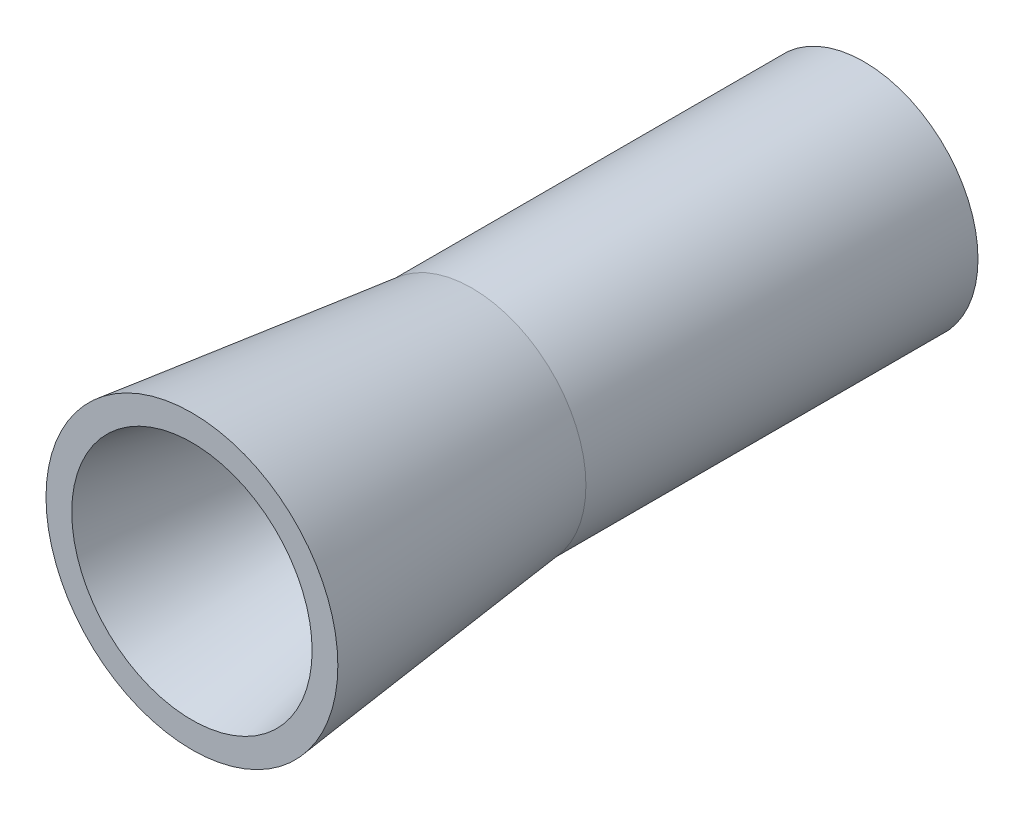
from build123d import *


with BuildPart() as part:
    # Sketch56 → Revolve1 (revolve)
    with BuildSketch(Plane(origin=(0, 0, 0), x_dir=(0, 0, -1), z_dir=(1, 0, 0))):
        Polygon((954.248849632, 397.569923116), (954.248849632, 372.871172083), (1200.354261712, 320.827375263), (1453.24665134, 320.827375263), (1599.130492084, 336.71334147), (1599.130492084, 366.85463088), (1222.967200249, 366.85463088), align=None)
    revolve(axis=Axis((0, 257.561673271, -1614.305416091), (0, 0, 1)))


solid = part.part
